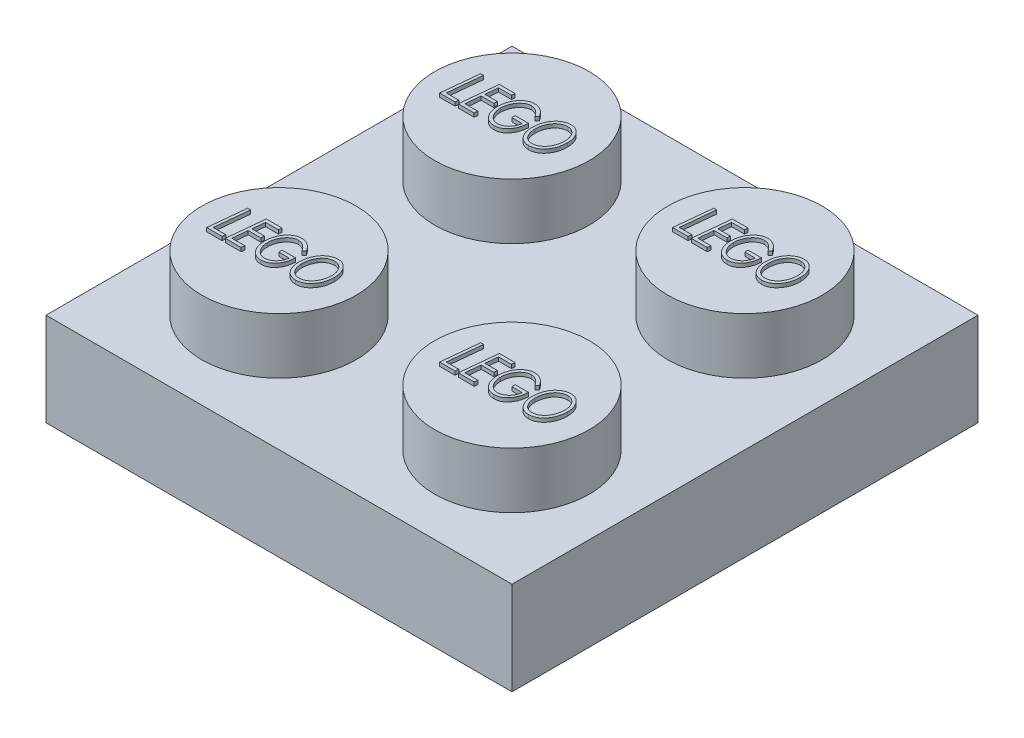
from build123d import *

# Parameters (mm, degrees)
SKETCH2_W            = 15.875
SKETCH2_H            = 15.875
BOSS_EXTRUDE3_DEPTH  = 3.175
SKETCH3_R            = 2.630752939
BOSS_EXTRUDE4_DEPTH  = 1.905
LPATTERN1_COUNT      = 2
LPATTERN1_PITCH      = 7.9375
LPATTERN1_COUNT_DIR2 = 2
LPATTERN1_PITCH_DIR2 = 7.9375
SHELL1_T             = -1.524
BOSS_EXTRUDE5_DEPTH  = 0.127
LPATTERN2_COUNT      = 2
LPATTERN2_PITCH      = 7.9375
LPATTERN2_COUNT_DIR2 = 2
LPATTERN2_PITCH_DIR2 = 7.9375
SKETCH5_R            = 3.175
SKETCH5_R_2          = 2.3876
BOSS_EXTRUDE6_DEPTH  = 1.651


with BuildPart() as part:
    # Sketch2 → Boss-Extrude3 (new body)
    with BuildSketch(Plane(origin=(0, 0, 0), x_dir=(1, 0, 0), z_dir=(0, 1, 0))):
        with Locations((-9.795613381, 0.785891089)):
            Rectangle(SKETCH2_W, SKETCH2_H)
    extrude(amount=BOSS_EXTRUDE3_DEPTH)

    # Sketch3 → Boss-Extrude4 (add)
    with BuildSketch(Plane(origin=(0, 3.175, 0), x_dir=(1, 0, 0), z_dir=(0, 1, 0))):
        with Locations((-13.764363381, 4.754641089)):
            Circle(SKETCH3_R)
    boss_extrude4 = extrude(amount=BOSS_EXTRUDE4_DEPTH)

    # LPattern1: Boss-Extrude4 2 × 2
    with Locations(*[(i * LPATTERN1_PITCH, 0, j * LPATTERN1_PITCH_DIR2) for i in range(LPATTERN1_COUNT) for j in range(LPATTERN1_COUNT_DIR2) if (i, j) != (0, 0)]):
        add(boss_extrude4)

    # Shell1
    shell1_openings = [part.faces().sort_by_distance(p)[0] for p in [
        (-9.795613381, 0, -0.785891089),
    ]]
    offset(amount=SHELL1_T, openings=shell1_openings, kind=Kind.INTERSECTION)

    # Sketch4 → Boss-Extrude5 (add)
    with BuildSketch(Plane(origin=(0, 5.08, 0), x_dir=(1, 0, 0), z_dir=(0, 1, 0))):
        Polygon((-15.421955913, 5.34660841), (-15.323500384, 5.34660841), (-15.441290849, 4.190582769), (-15.01414141, 4.190582769), (-15.02533532, 4.07660841), (-15.551449102, 4.07660841), align=None)
        Polygon((-14.248885, 5.34660841), (-14.262877387, 5.232634051), (-14.699694294, 5.232634051), (-14.742943493, 4.809300718), (-14.314013205, 4.809300718), (-14.326733557, 4.695326359), (-14.754646217, 4.695326359), (-14.806036442, 4.190582769), (-14.362859359, 4.190582769), (-14.374307676, 4.07660841), (-14.916449102, 4.07660841), (-14.786701506, 5.34660841), align=None)
        with BuildLine():
            Line((-13.157987564, 5.079226599), (-13.23685375, 5.004685333))
            add(Edge.make_bspline(
                [(-13.23685375, 5.004685333), (-13.243036349, 5.014919943), (-13.255215537, 5.03508124), (-13.274843903, 5.0639219), (-13.295404966, 5.090766309), (-13.316668722, 5.115943823), (-13.338681843, 5.139287343), (-13.361588027, 5.160749301), (-13.385450265, 5.180091456), (-13.409701872, 5.197942406), (-13.434658284, 5.213660022), (-13.459747782, 5.227481566), (-13.485177989, 5.238904833), (-13.510565197, 5.248734726), (-13.536282118, 5.256136896), (-13.562187777, 5.261089256), (-13.588089761, 5.264689825), (-13.605477312, 5.265029123), (-13.614139407, 5.265198154)],
                knots=[0, 0, 0, 0, 3.5867e-05, 7.0655e-05, 0.000104594, 0.000137266, 0.00016948, 0.0002008, 0.000231355, 0.000261581, 0.000291084, 0.000319773, 0.000347439, 0.000374655, 0.000401388, 0.000427582, 0.000453742, 0.000479711, 0.000479711, 0.000479711, 0.000479711], degree=3))
            add(Edge.make_bspline(
                [(-13.614139407, 5.265198154), (-13.623817018, 5.264942089), (-13.643246281, 5.264428001), (-13.672242613, 5.260605848), (-13.70083591, 5.253771652), (-13.729278127, 5.244988175), (-13.757272205, 5.233098144), (-13.785048709, 5.218900423), (-13.812373825, 5.20184576), (-13.839460855, 5.182752056), (-13.865426178, 5.16117013), (-13.890266569, 5.13792049), (-13.91359838, 5.112994152), (-13.935710508, 5.086452282), (-13.955872189, 5.057845897), (-13.975112242, 5.027830316), (-13.992587445, 4.995991744), (-14.008566347, 4.962671117), (-14.023015409, 4.928317995), (-14.035508966, 4.893155428), (-14.045942052, 4.857372561), (-14.054589121, 4.820944025), (-14.06149942, 4.783854091), (-14.066312673, 4.746142046), (-14.069143076, 4.707836031), (-14.069568079, 4.682101861), (-14.069782435, 4.669122433)],
                knots=[0, 0, 0, 0, 2.903e-05, 5.8283e-05, 8.7534e-05, 0.000117144, 0.000147477, 0.000178653, 0.000210636, 0.000244026, 0.000278, 0.000311837, 0.000346034, 0.000380367, 0.000415383, 0.000450953, 0.000487277, 0.000524259, 0.000561774, 0.000599029, 0.000636142, 0.000673537, 0.00071131, 0.000749271, 0.000787535, 0.000826472, 0.000826472, 0.000826472, 0.000826472], degree=3))
            add(Edge.make_bspline(
                [(-14.069782435, 4.669122433), (-14.069477418, 4.651721569), (-14.068877636, 4.617504752), (-14.063037479, 4.567164063), (-14.053971473, 4.518756671), (-14.041310983, 4.472223428), (-14.024646127, 4.42784351), (-14.004569657, 4.385349364), (-13.980409537, 4.345047805), (-13.953305264, 4.306998763), (-13.923509762, 4.272231716), (-13.891611692, 4.241833165), (-13.858241554, 4.215836332), (-13.822960448, 4.194859762), (-13.786317389, 4.177985595), (-13.747701019, 4.166780357), (-13.707804487, 4.159194772), (-13.680575585, 4.158413751), (-13.666801666, 4.158018667)],
                knots=[0, 0, 0, 0, 5.2184e-05, 0.000102614, 0.000151811, 0.000199829, 0.000247083, 0.000293853, 0.000340625, 0.000387856, 0.000433855, 0.000477763, 0.000519845, 0.000560465, 0.000600659, 0.0006405, 0.000680822, 0.0007221, 0.0007221, 0.0007221, 0.0007221], degree=3))
            add(Edge.make_bspline(
                [(-13.666801666, 4.158018667), (-13.650119891, 4.158598006), (-13.616764989, 4.159756384), (-13.567583001, 4.170959003), (-13.519199429, 4.187625511), (-13.472815147, 4.211693168), (-13.428975753, 4.24107788), (-13.3888146, 4.275137052), (-13.353443755, 4.314132031), (-13.322014522, 4.35741319), (-13.295472287, 4.406100752), (-13.27204085, 4.459501556), (-13.253441597, 4.518549092), (-13.244174766, 4.559989791), (-13.23939782, 4.581352)],
                knots=[0, 0, 0, 0, 4.9973e-05, 9.9921e-05, 0.000150611, 0.000203177, 0.000256167, 0.000308679, 0.000360721, 0.000413748, 0.000468753, 0.000526746, 0.000588456, 0.000654111, 0.000654111, 0.000654111, 0.000654111], degree=3))
            Line((-13.23939782, 4.581352), (-13.597602948, 4.581352))
            Line((-13.597602948, 4.581352), (-13.597602948, 4.695326359))
            Line((-13.597602948, 4.695326359), (-13.141705512, 4.695326359))
            add(Edge.make_bspline(
                [(-13.141705512, 4.695326359), (-13.143220249, 4.671630935), (-13.14618471, 4.625257073), (-13.156473523, 4.557663764), (-13.169882793, 4.493369383), (-13.188032162, 4.432650411), (-13.210191974, 4.37537214), (-13.236456597, 4.321477624), (-13.266757599, 4.270933421), (-13.300959259, 4.224225256), (-13.338414001, 4.182195788), (-13.37822362, 4.145176879), (-13.420442551, 4.113917018), (-13.464913787, 4.088167818), (-13.511934995, 4.06856876), (-13.561029266, 4.05415967), (-13.612484302, 4.045619356), (-13.647519936, 4.044574047), (-13.665275224, 4.044044308)],
                knots=[0, 0, 0, 0, 7.12e-05, 0.000139344, 0.00020491, 0.000268096, 0.00032923, 0.000388964, 0.000447735, 0.000505793, 0.000562373, 0.000616384, 0.000668589, 0.000719646, 0.000770156, 0.000821037, 0.000872858, 0.000926102, 0.000926102, 0.000926102, 0.000926102], degree=3))
            add(Edge.make_bspline(
                [(-13.665275224, 4.044044308), (-13.683458795, 4.044552296), (-13.719178417, 4.045550182), (-13.771372456, 4.054296421), (-13.821069071, 4.067841152), (-13.868065514, 4.087506656), (-13.912556407, 4.112374207), (-13.953984263, 4.143464588), (-13.993154071, 4.179412869), (-14.029026836, 4.220871562), (-14.061293356, 4.26652386), (-14.090007965, 4.315160597), (-14.113916063, 4.366865748), (-14.133555901, 4.421262957), (-14.148827293, 4.478548833), (-14.159713516, 4.538607223), (-14.166095756, 4.601566492), (-14.167008525, 4.644430286), (-14.167474743, 4.666323955)],
                knots=[0, 0, 0, 0, 5.4515e-05, 0.000107089, 0.00015832, 0.000208732, 0.000259537, 0.000310826, 0.000363759, 0.000418756, 0.000474947, 0.000531277, 0.000587959, 0.00064558, 0.000704576, 0.000765604, 0.000828511, 0.000894188, 0.000894188, 0.000894188, 0.000894188], degree=3))
            add(Edge.make_bspline(
                [(-14.167474743, 4.666323955), (-14.167185589, 4.682101713), (-14.16661133, 4.713436248), (-14.163381594, 4.759994442), (-14.157432775, 4.805749539), (-14.149274332, 4.850644315), (-14.139160769, 4.894945835), (-14.126422318, 4.938327925), (-14.111352878, 4.98094547), (-14.094155797, 5.022494256), (-14.074869439, 5.062577802), (-14.053847868, 5.100800933), (-14.03078607, 5.136684011), (-14.006484206, 5.170754132), (-13.979939226, 5.202226268), (-13.951836475, 5.231556391), (-13.922318071, 5.259016319), (-13.890824475, 5.283795413), (-13.858123028, 5.306042524), (-13.824881044, 5.325834039), (-13.790743443, 5.34211596), (-13.756112763, 5.355771227), (-13.720646944, 5.366079712), (-13.684726153, 5.373904452), (-13.648081628, 5.378221983), (-13.623478046, 5.378854133), (-13.611086522, 5.379172513)],
                knots=[0, 0, 0, 0, 4.7337e-05, 9.4011e-05, 0.000139924, 0.000185684, 0.000230857, 0.000276183, 0.000321242, 0.000366409, 0.000411014, 0.000454628, 0.000497184, 0.000538913, 0.000580086, 0.000620572, 0.000660721, 0.00070093, 0.000740658, 0.000779316, 0.000816866, 0.000854, 0.000890868, 0.000927543, 0.000964179, 0.001001354, 0.001001354, 0.001001354, 0.001001354], degree=3))
            add(Edge.make_bspline(
                [(-13.611086522, 5.379172513), (-13.599885481, 5.378887615), (-13.577690409, 5.378323085), (-13.544759644, 5.375041802), (-13.512580278, 5.369229816), (-13.481226926, 5.36060081), (-13.450309917, 5.350370482), (-13.420236456, 5.337162127), (-13.39072561, 5.322040578), (-13.362124517, 5.304229546), (-13.334002379, 5.284471776), (-13.306931369, 5.261858803), (-13.280001622, 5.237508559), (-13.254169985, 5.210414835), (-13.228831131, 5.181124192), (-13.20464202, 5.149192743), (-13.18043895, 5.115396141), (-13.16557029, 5.091442492), (-13.157987564, 5.079226599)],
                knots=[0, 0, 0, 0, 3.3606e-05, 6.6591e-05, 9.9176e-05, 0.000131574, 0.000164077, 0.000196781, 0.000230006, 0.000263473, 0.000297779, 0.000333024, 0.000369219, 0.000406644, 0.000445248, 0.000485345, 0.000526779, 0.000569901, 0.000569901, 0.000569901, 0.000569901], degree=3))
        make_face()
        with BuildLine():
            add(Edge.make_bspline(
                [(-12.369325705, 5.379172513), (-12.353010143, 5.378720522), (-12.32085994, 5.377829863), (-12.273715249, 5.369659659), (-12.22864765, 5.356507424), (-12.185856311, 5.337650018), (-12.145072326, 5.313842859), (-12.10647493, 5.284550539), (-12.070049375, 5.250024202), (-12.036169842, 5.210647693), (-12.00531375, 5.167406166), (-11.978235129, 5.120902684), (-11.955360597, 5.071642915), (-11.936357429, 5.019696609), (-11.921887955, 4.964835989), (-11.911994605, 4.907187182), (-11.905270318, 4.84685662), (-11.904608097, 4.805673345), (-11.904269615, 4.784623234)],
                knots=[0, 0, 0, 0, 4.8912e-05, 9.6383e-05, 0.000143072, 0.00018944, 0.000236302, 0.000284436, 0.000334467, 0.000386593, 0.000440034, 0.000493616, 0.000547793, 0.000602762, 0.000659349, 0.000717739, 0.000778115, 0.000841241, 0.000841241, 0.000841241, 0.000841241], degree=3))
            add(Edge.make_bspline(
                [(-11.904269615, 4.784623234), (-11.904724813, 4.758992871), (-11.905619371, 4.708623908), (-11.913649979, 4.634691374), (-11.926918957, 4.563951657), (-11.945042207, 4.49615546), (-11.969268607, 4.431731122), (-11.997812291, 4.369990143), (-12.032508136, 4.311855249), (-12.071636526, 4.257287391), (-12.11438555, 4.207292778), (-12.160684455, 4.163785264), (-12.209491268, 4.12681072), (-12.260952984, 4.096525947), (-12.315022525, 4.072933007), (-12.371712054, 4.05602052), (-12.43112154, 4.045889546), (-12.47164277, 4.044665448), (-12.49220431, 4.044044308)],
                knots=[0, 0, 0, 0, 7.6873e-05, 0.000151071, 0.000222773, 0.000292635, 0.000361299, 0.000429016, 0.000496426, 0.000564063, 0.000630262, 0.000693435, 0.00075429, 0.000813586, 0.000872147, 0.000930825, 0.000990675, 0.00105233, 0.00105233, 0.00105233, 0.00105233], degree=3))
            add(Edge.make_bspline(
                [(-12.49220431, 4.044044308), (-12.509616292, 4.04451494), (-12.543682005, 4.04543571), (-12.593480052, 4.053188575), (-12.640452828, 4.066244037), (-12.684989099, 4.084066344), (-12.726670432, 4.107489433), (-12.765818741, 4.135865921), (-12.802122503, 4.169487075), (-12.83534682, 4.207966726), (-12.865201071, 4.250535984), (-12.891189794, 4.296615807), (-12.91347966, 4.345682347), (-12.931507817, 4.398084844), (-12.945433182, 4.453595942), (-12.955221104, 4.512216375), (-12.961524863, 4.573921358), (-12.962237892, 4.616189815), (-12.962602948, 4.637830365)],
                knots=[0, 0, 0, 0, 5.2215e-05, 0.000102157, 0.000150733, 0.000198212, 0.000245705, 0.000293794, 0.000342944, 0.000393802, 0.000446031, 0.000498666, 0.000552293, 0.000607486, 0.000664684, 0.000723782, 0.000785651, 0.000850556, 0.000850556, 0.000850556, 0.000850556], degree=3))
            add(Edge.make_bspline(
                [(-12.962602948, 4.637830365), (-12.962348656, 4.654713021), (-12.961844621, 4.68817633), (-12.958119133, 4.737832996), (-12.952514622, 4.786550271), (-12.943616351, 4.83402181), (-12.933066316, 4.8806248), (-12.919782503, 4.926031082), (-12.904304725, 4.970508016), (-12.88616901, 5.013561667), (-12.866377445, 5.055186009), (-12.843997862, 5.094446642), (-12.820275911, 5.131646309), (-12.79433308, 5.166341896), (-12.767012283, 5.199072462), (-12.737321482, 5.229081319), (-12.705989763, 5.256911788), (-12.672917443, 5.282323432), (-12.638580562, 5.305193307), (-12.602929741, 5.324828759), (-12.566454338, 5.341794401), (-12.528918438, 5.355489869), (-12.490336002, 5.365956739), (-12.450894272, 5.373598515), (-12.410399159, 5.378302894), (-12.383076102, 5.378881385), (-12.369325705, 5.379172513)],
                knots=[0, 0, 0, 0, 5.0643e-05, 0.00010038, 0.000149323, 0.000197677, 0.000245196, 0.000292617, 0.000339526, 0.000386395, 0.000432706, 0.000477705, 0.000521881, 0.000564978, 0.000607585, 0.000649681, 0.000691492, 0.000733218, 0.000774708, 0.000815134, 0.000855202, 0.000895282, 0.000934843, 0.000975008, 0.001015717, 0.001056959, 0.001056959, 0.001056959, 0.001056959], degree=3))
        make_face()
        with BuildLine():
            add(Edge.make_bspline(
                [(-12.37059774, 5.265198154), (-12.382313596, 5.264974538), (-12.405384953, 5.264534185), (-12.43952799, 5.260405022), (-12.472806234, 5.254641281), (-12.50500305, 5.2453884), (-12.53641925, 5.23449868), (-12.566541003, 5.220073421), (-12.596086752, 5.204049224), (-12.624325369, 5.185085614), (-12.651275466, 5.163901314), (-12.677105719, 5.1407675), (-12.701242778, 5.115240955), (-12.723914887, 5.087622005), (-12.745319033, 5.058107871), (-12.765258418, 5.02643651), (-12.783453767, 4.992497975), (-12.800435903, 4.956872571), (-12.815618513, 4.919838387), (-12.828923446, 4.882001808), (-12.839728639, 4.843441788), (-12.848995625, 4.804516904), (-12.856130352, 4.764939705), (-12.861169544, 4.724771762), (-12.864339072, 4.683929196), (-12.8647191, 4.656492627), (-12.864910641, 4.642664099)],
                knots=[0, 0, 0, 0, 3.5131e-05, 6.9182e-05, 0.000103064, 0.000136333, 0.000169567, 0.000202688, 0.000236393, 0.000270332, 0.000304582, 0.000339169, 0.000374259, 0.000409863, 0.000446299, 0.000483568, 0.000522044, 0.000561759, 0.000601917, 0.000642065, 0.000682008, 0.000721995, 0.000762067, 0.000802584, 0.000843403, 0.000884884, 0.000884884, 0.000884884, 0.000884884], degree=3))
            add(Edge.make_bspline(
                [(-12.864910641, 4.642664099), (-12.864307988, 4.619656102), (-12.863131603, 4.574744224), (-12.854429419, 4.509171597), (-12.839695903, 4.447271889), (-12.822395219, 4.398577377), (-12.806018379, 4.361918699), (-12.792619836, 4.336186177), (-12.777779937, 4.312362342), (-12.762246178, 4.289966829), (-12.745390246, 4.269317365), (-12.727389498, 4.250238819), (-12.708171153, 4.232904881), (-12.688073445, 4.216982903), (-12.666766853, 4.20305699), (-12.644505145, 4.191085763), (-12.621414016, 4.180768501), (-12.597334266, 4.172401088), (-12.572284701, 4.166087649), (-12.546442494, 4.161495703), (-12.519659259, 4.158635539), (-12.50145487, 4.158226513), (-12.49220431, 4.158018667)],
                knots=[0, 0, 0, 0, 6.9012e-05, 0.000134712, 0.000198022, 0.000259579, 0.000289414, 0.000318432, 0.000346532, 0.000373564, 0.000400145, 0.00042642, 0.000452175, 0.000477724, 0.000503267, 0.000528424, 0.00055348, 0.000579065, 0.000604796, 0.000630896, 0.000657755, 0.000685504, 0.000685504, 0.000685504, 0.000685504], degree=3))
            add(Edge.make_bspline(
                [(-12.49220431, 4.158018667), (-12.481164543, 4.158226379), (-12.45926255, 4.158638462), (-12.426815915, 4.163069526), (-12.394912776, 4.169171543), (-12.363753517, 4.178557501), (-12.333054523, 4.1901992), (-12.30315314, 4.204836709), (-12.27362727, 4.221656145), (-12.245054493, 4.241259996), (-12.217396148, 4.263059149), (-12.191102552, 4.2869402), (-12.166751424, 4.31313992), (-12.143343282, 4.340857537), (-12.121926482, 4.370957713), (-12.101553921, 4.402800133), (-12.083509498, 4.437043875), (-12.066362584, 4.472756352), (-12.051268705, 4.510002211), (-12.037904005, 4.548157353), (-12.027111895, 4.587233797), (-12.017881689, 4.626845971), (-12.010718503, 4.667266057), (-12.005706916, 4.708370092), (-12.002526277, 4.750312827), (-12.002151397, 4.778511748), (-12.001961923, 4.79276426)],
                knots=[0, 0, 0, 0, 3.3097e-05, 6.5662e-05, 9.8093e-05, 0.000130454, 0.000163149, 0.000196488, 0.000230221, 0.000265008, 0.000300331, 0.000335806, 0.000371442, 0.000407566, 0.000444563, 0.000482183, 0.000520883, 0.000560598, 0.000600991, 0.00064138, 0.000681813, 0.000722543, 0.000763366, 0.000804893, 0.000846727, 0.000889479, 0.000889479, 0.000889479, 0.000889479], degree=3))
            add(Edge.make_bspline(
                [(-12.001961923, 4.79276426), (-12.002383429, 4.811264), (-12.003207157, 4.847417056), (-12.008729979, 4.900202516), (-12.018384404, 4.949996074), (-12.031884335, 4.996843587), (-12.049147304, 5.040781654), (-12.070413266, 5.081809748), (-12.095511146, 5.119934561), (-12.115257706, 5.142857206), (-12.125094935, 5.15427668)],
                knots=[0, 0, 0, 0, 5.5498e-05, 0.000108457, 0.000158999, 0.000207469, 0.000254523, 0.000300379, 0.00034589, 0.00039107, 0.00039107, 0.00039107, 0.00039107], degree=3))
            add(Edge.make_bspline(
                [(-12.125094935, 5.15427668), (-12.133669324, 5.163096064), (-12.150521626, 5.180429887), (-12.178137379, 5.203115094), (-12.206989058, 5.222389045), (-12.237249627, 5.237947562), (-12.268734009, 5.250365639), (-12.301624315, 5.258916547), (-12.335745739, 5.264150728), (-12.358876291, 5.264845883), (-12.37059774, 5.265198154)],
                knots=[0, 0, 0, 0, 3.6878e-05, 7.2482e-05, 0.000106986, 0.00014078, 0.00017437, 0.000208309, 0.000242526, 0.000277679, 0.000277679, 0.000277679, 0.000277679], degree=3))
        make_face(mode=Mode.SUBTRACT)
    boss_extrude5 = extrude(amount=BOSS_EXTRUDE5_DEPTH)

    # LPattern2: Boss-Extrude5 2 × 2
    with Locations(*[(i * LPATTERN2_PITCH, 0, j * LPATTERN2_PITCH_DIR2) for i in range(LPATTERN2_COUNT) for j in range(LPATTERN2_COUNT_DIR2) if (i, j) != (0, 0)]):
        add(boss_extrude5)

    # Sketch5 → Boss-Extrude6 (add)
    with BuildSketch(Plane.XZ):
        with Locations((-9.795613381, -0.785891089)):
            Circle(SKETCH5_R)
        with Locations((-9.795613381, -0.785891089)):
            Circle(SKETCH5_R_2, mode=Mode.SUBTRACT)
    extrude(amount=-BOSS_EXTRUDE6_DEPTH)


solid = part.part
